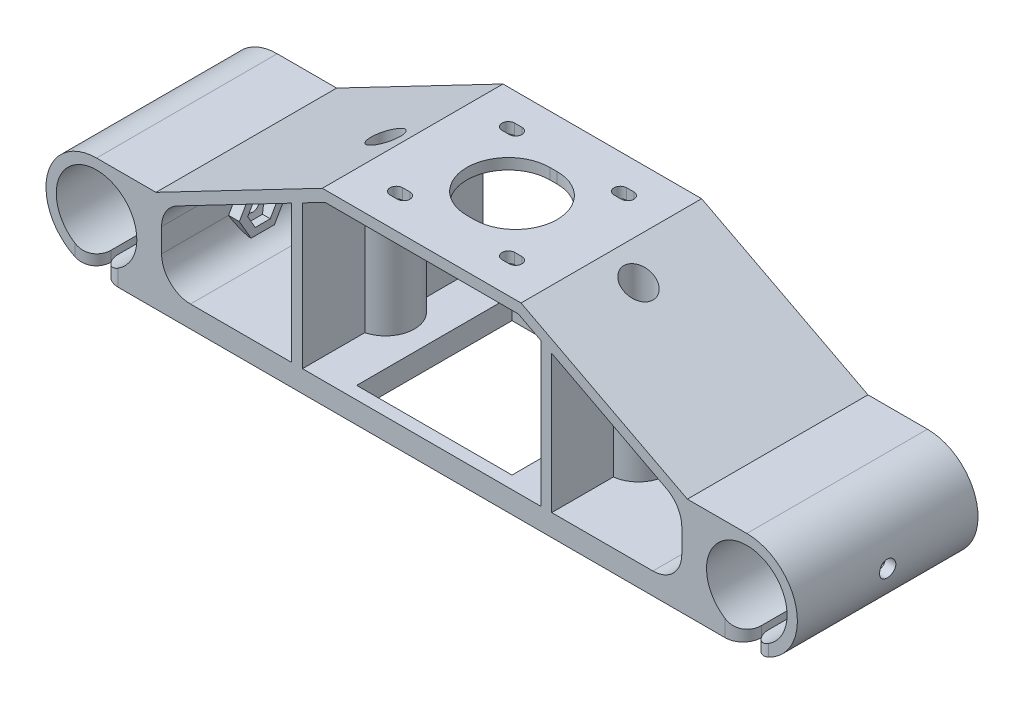
from build123d import *

# Parameters (mm, degrees)
SKETCH1_R               = 11.15
BOSS_EXTRUDE1_DEPTH     = 50
CUT_EXTRUDE1_DEPTH      = 26
SKETCH3_W               = 43
SKETCH3_H               = 43
CUT_EXTRUDE2_DEPTH      = 26
BOSS_EXTRUDE3_REACH     = 48
SKETCH4_R               = 8
SKETCH5_R               = 4.05
CUT_EXTRUDE3_DEPTH      = 43
CUT_EXTRUDE4_DEPTH      = 3
FILLET1_R               = 8
BOSS_EXTRUDE4_DEPTH     = 3
CUT_EXTRUDE5_START      = -33
SKETCH8_R               = 2.25
CUT_EXTRUDE5_DEPTH      = 77
BOSS_EXTRUDE5_DEPTH     = 3
CUT_EXTRUDE_THIN1_START = -10
SKETCH10_W              = 2
SKETCH10_H              = 50
CUT_EXTRUDE_THIN1_DEPTH = 11.0000001
FILLET2_R               = 5


with BuildPart() as part:
    # Sketch1 → Boss-Extrude1 (new body)
    with BuildSketch(Plane.XY):
        with BuildLine():
            Line((0, -14), (180, -14))
            ThreePointArc((180, -14), (194, 0), (180, 14))
            Line((180, 14), (163.542940407, 14))
            Line((163.542940407, 14), (117.5, 38))
            Line((117.5, 38), (62.5, 38))
            Line((62.5, 38), (16.457059593, 14))
            Line((16.457059593, 14), (0, 14))
            ThreePointArc((0, 14), (-14, 0), (0, -14))
        make_face()
        Circle(SKETCH1_R, mode=Mode.SUBTRACT)
        with Locations((180, 0)):
            Circle(SKETCH1_R, mode=Mode.SUBTRACT)
        Polygon((18, 11.421165704), (18, -8), (162, -8), (162, 11.421165704), (116.765047401, 35), (63.234952599, 35), align=None, mode=Mode.SUBTRACT)
    extrude(amount=BOSS_EXTRUDE1_DEPTH)

    # Sketch2 → Cut-Extrude1 (cut)
    with BuildSketch(Plane(origin=(0, 38, 0), x_dir=(1, 0, 0), z_dir=(0, 1, 0))):
        with BuildLine():
            Line((89, -13.5), (91, -13.5))
            ThreePointArc((91, -13.5), (102.5, -25), (91, -36.5))
            Line((91, -36.5), (89, -36.5))
            ThreePointArc((89, -36.5), (77.5, -25), (89, -13.5))
        make_face()
        with BuildLine():
            Line((73.5, -7.75), (75.5, -7.75))
            ThreePointArc((75.5, -7.75), (77.25, -9.5), (75.5, -11.25))
            Line((75.5, -11.25), (73.5, -11.25))
            ThreePointArc((73.5, -11.25), (71.75, -9.5), (73.5, -7.75))
        make_face()
        with BuildLine():
            Line((104.5, -7.75), (106.5, -7.75))
            ThreePointArc((106.5, -7.75), (108.25, -9.5), (106.5, -11.25))
            Line((106.5, -11.25), (104.5, -11.25))
            ThreePointArc((104.5, -11.25), (102.75, -9.5), (104.5, -7.75))
        make_face()
        with BuildLine():
            Line((104.5, -38.75), (106.5, -38.75))
            ThreePointArc((106.5, -38.75), (108.25, -40.5), (106.5, -42.25))
            Line((106.5, -42.25), (104.5, -42.25))
            ThreePointArc((104.5, -42.25), (102.75, -40.5), (104.5, -38.75))
        make_face()
        with BuildLine():
            Line((73.5, -38.75), (75.5, -38.75))
            ThreePointArc((75.5, -38.75), (77.25, -40.5), (75.5, -42.25))
            Line((75.5, -42.25), (73.5, -42.25))
            ThreePointArc((73.5, -42.25), (71.75, -40.5), (73.5, -38.75))
        make_face()
    extrude(amount=-CUT_EXTRUDE1_DEPTH, mode=Mode.SUBTRACT)

    # Sketch3 → Cut-Extrude2 (cut)
    with BuildSketch(Plane(origin=(0, -8, 0), x_dir=(1, 0, 0), z_dir=(0, 1, 0))):
        with Locations((90, -25)):
            Rectangle(SKETCH3_W, SKETCH3_H)
    extrude(amount=-CUT_EXTRUDE2_DEPTH, mode=Mode.SUBTRACT)

    # Sketch4 → Boss-Extrude3 (add, up to next)
    with BuildSketch(Plane(origin=(0, -8, 0), x_dir=(1, 0, 0), z_dir=(0, 1, 0)), mode=Mode.PRIVATE) as boss_extrude3_sk1:
        with Locations((55, -25)):
            Circle(SKETCH4_R)
    boss_extrude3_tool1 = extrude(boss_extrude3_sk1.sketch, amount=BOSS_EXTRUDE3_REACH, mode=Mode.PRIVATE) - part.part
    add(boss_extrude3_tool1.solids().sort_by_distance((55, -8, 25))[0])
    # Sketch4 → Boss-Extrude3 (add, up to next)
    with BuildSketch(Plane(origin=(0, -8, 0), x_dir=(1, 0, 0), z_dir=(0, 1, 0)), mode=Mode.PRIVATE) as boss_extrude3_sk2:
        with Locations((125, -25)):
            Circle(SKETCH4_R)
    boss_extrude3_tool2 = extrude(boss_extrude3_sk2.sketch, amount=BOSS_EXTRUDE3_REACH, mode=Mode.PRIVATE) - part.part
    add(boss_extrude3_tool2.solids().sort_by_distance((125, -8, 25))[0])

    # Sketch5 → Cut-Extrude3 (cut)
    with BuildSketch(Plane(origin=(0, 38, 0), x_dir=(1, 0, 0), z_dir=(0, 1, 0))):
        with Locations((55, -25)):
            Circle(SKETCH5_R)
        with Locations((125, -25)):
            Circle(SKETCH5_R)
    extrude(amount=-CUT_EXTRUDE3_DEPTH, mode=Mode.SUBTRACT)

    # Sketch7 → Cut-Extrude4 (cut)
    with BuildSketch(Plane(origin=(0, -14, 0), x_dir=(-1, 0, 0), z_dir=(0, -1, 0))):
        with BuildLine():
            Line((-10, -46.5), (-58.5, -46.5))
            ThreePointArc((-58.5, -46.5), (-62.035533906, -45.035533906), (-63.5, -41.5))
            Line((-63.5, -41.5), (-63.5, -8.5))
            ThreePointArc((-63.5, -8.5), (-62.035533906, -4.964466094), (-58.5, -3.5))
            Line((-58.5, -3.5), (-10, -3.5))
            ThreePointArc((-10, -3.5), (-6.464466094, -4.964466094), (-5, -8.5))
            Line((-5, -8.5), (-5, -41.5))
            ThreePointArc((-5, -41.5), (-6.464466094, -45.035533906), (-10, -46.5))
        make_face()
    cut_extrude4 = extrude(amount=-CUT_EXTRUDE4_DEPTH, mode=Mode.SUBTRACT)

    # Mirror2: Cut-Extrude4 across plane
    add(cut_extrude4.mirror(Plane(origin=(90, 0, 0), x_dir=(0, 0, 1), z_dir=(1, 0, 0))), mode=Mode.SUBTRACT)

    # Fillet1
    fillet1_edges = [part.edges().sort_by_distance(p)[0] for p in [
        (18, -8, 25),
        (162, -8, 25),
        (162, 11.421165704, 25),
        (18, 11.421165704, 25),
    ]]
    fillet(fillet1_edges, radius=FILLET1_R)

    # Sketch6 → Boss-Extrude4 (add)
    with BuildSketch(Plane(origin=(123, 0, 0), x_dir=(0, 0, -1), z_dir=(1, 0, 0))):
        Polygon((-17.254033308, 31.750015072), (-17.254033308, -8), (0, -8), (0, 27.389676514), (0, 31.750015072), align=None)
        Polygon((-32.745966692, -8), (-32.745966692, 31.750015072), (-50, 31.750015072), (-50, 27.389676514), (-50, -8), align=None)
    boss_extrude4 = extrude(amount=BOSS_EXTRUDE4_DEPTH)

    # Mirror3: Boss-Extrude4 across plane
    add(boss_extrude4.mirror(Plane(origin=(90, 0, 0), x_dir=(0, 0, 1), z_dir=(1, 0, 0))))

    # Sketch8 → Cut-Extrude5 (cut)
    with BuildSketch(Plane.ZY.offset(-180).offset(CUT_EXTRUDE5_START)):
        with Locations((25, 0)):
            Circle(SKETCH8_R)
    cut_extrude5 = extrude(amount=CUT_EXTRUDE5_DEPTH, mode=Mode.SUBTRACT)

    # Sketch9 → Boss-Extrude5 (add)
    with BuildSketch(Plane.ZY.offset(-162)):
        Polygon((18.533676985, 0), (21.766838493, -5.6), (28.233161507, -5.6), (31.466323015, 0), (28.233161507, 5.6), (21.766838493, 5.6), align=None)
        Polygon((20.843078062, 0), (22.921539031, -3.6), (27.078460969, -3.6), (29.156921938, 0), (27.078460969, 3.6), (22.921539031, 3.6), align=None, mode=Mode.SUBTRACT)
    boss_extrude5 = extrude(amount=BOSS_EXTRUDE5_DEPTH)

    # Mirror4: Cut-Extrude5, Boss-Extrude5 across plane
    add(cut_extrude5.mirror(Plane(origin=(90, 0, 0), x_dir=(0, 0, 1), z_dir=(1, 0, 0))), mode=Mode.SUBTRACT)
    add(boss_extrude5.mirror(Plane(origin=(90, 0, 0), x_dir=(0, 0, 1), z_dir=(1, 0, 0))))

    # Sketch10 → Cut-Extrude-Thin1 (cut)
    with BuildSketch(Plane(origin=(0, -14, 0), x_dir=(-1, 0, 0), z_dir=(0, -1, 0)).offset(CUT_EXTRUDE_THIN1_START)):
        with Locations((0, -25)):
            Rectangle(SKETCH10_W, SKETCH10_H)
    cut_extrude_thin1 = extrude(amount=CUT_EXTRUDE_THIN1_DEPTH, mode=Mode.SUBTRACT)

    # Mirror5: Cut-Extrude-Thin1 across plane
    add(cut_extrude_thin1.mirror(Plane(origin=(90, 0, 0), x_dir=(0, 0, 1), z_dir=(1, 0, 0))), mode=Mode.SUBTRACT)

    # Fillet2
    fillet2_edges = [part.edges().sort_by_distance(p)[0] for p in [
        (1, -12.552533206, 0),
        (1, -12.552533206, 50),
        (-1, -12.534653228, 50),
        (-1, -12.534653228, 0),
        (179, -12.552533206, 50),
        (179, -12.552533206, 0),
        (181, -12.534653228, 0),
        (181, -12.534653228, 50),
    ]]
    fillet(fillet2_edges, radius=FILLET2_R)


solid = part.part
